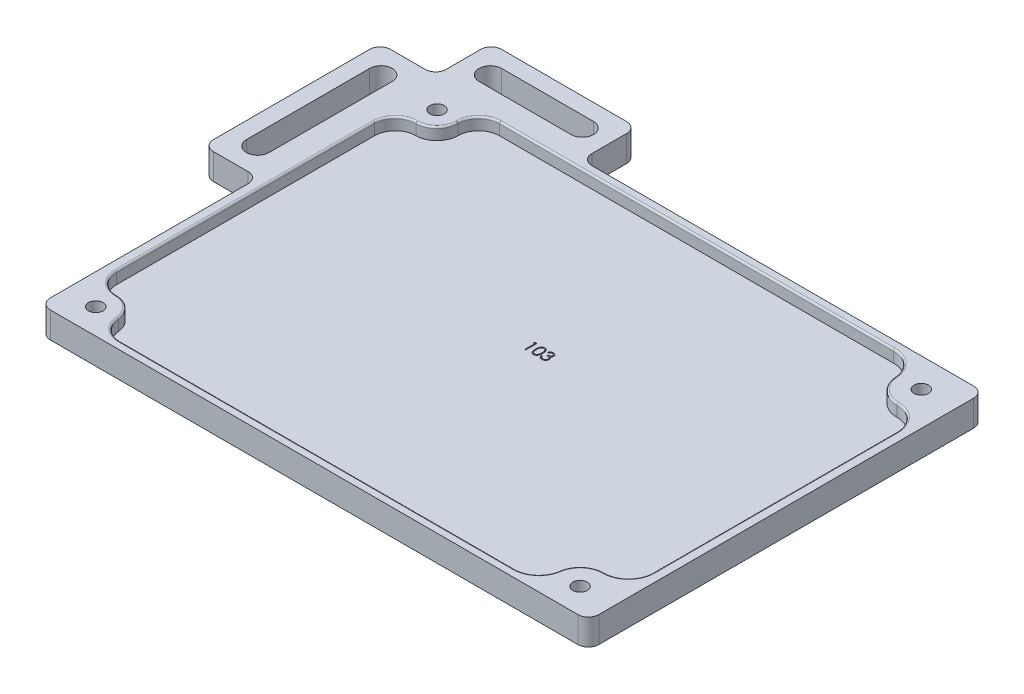
from build123d import *

# Parameters (mm, degrees)
SKETCH1_W           = 158
SKETCH1_H           = 114
SKETCH1_R           = 2.09
BOSS_EXTRUDE1_DEPTH = 7.5
SKETCH1_2_R         = 2.09
BOSS_EXTRUDE2_DEPTH = 2
CUT_EXTRUDE1_DEPTH  = 3.5
SKETCH3_W           = 42
SKETCH3_H           = 16
SKETCH3_W_2         = 16
SKETCH3_H_2         = 51
BOSS_EXTRUDE3_DEPTH = 7.5
FILLET1_R           = 0.5
FILLET2_R           = 3
CUT_EXTRUDE2_DEPTH  = 1


with BuildPart() as part:
    # Sketch1 → Boss-Extrude1 (new body)
    with BuildSketch(Plane(origin=(0, 0, 0), x_dir=(1, 0, 0), z_dir=(0, 1, 0))):
        with Locations((79, 57)):
            Rectangle(SKETCH1_W, SKETCH1_H)
        with Locations((8.75, 105.65)):
            Circle(SKETCH1_R, mode=Mode.SUBTRACT)
        with Locations((8.75, 7.35)):
            Circle(SKETCH1_R, mode=Mode.SUBTRACT)
        with Locations((148.25, 7.35)):
            Circle(SKETCH1_R, mode=Mode.SUBTRACT)
        with Locations((148.25, 105.65)):
            Circle(SKETCH1_R, mode=Mode.SUBTRACT)
    extrude(amount=BOSS_EXTRUDE1_DEPTH)

    # Sketch1_2 → Boss-Extrude2 (add)
    with BuildSketch(Plane(origin=(0, 0, 0), x_dir=(1, 0, 0), z_dir=(0, 1, 0))):
        with Locations((8.75, 105.65)):
            Circle(SKETCH1_2_R)
        with Locations((148.25, 105.65)):
            Circle(SKETCH1_2_R)
        with Locations((8.75, 7.35)):
            Circle(SKETCH1_2_R)
        with Locations((148.25, 7.35)):
            Circle(SKETCH1_2_R)
    extrude(amount=BOSS_EXTRUDE2_DEPTH)

    # Sketch2 → Cut-Extrude1 (cut)
    with BuildSketch(Plane(origin=(0, 7.5, 0), x_dir=(1, 0, 0), z_dir=(0, 1, 0))):
        with BuildLine():
            Line((20.708260743, 2.35), (134.393593539, 2.35))
            ThreePointArc((134.393593539, 2.35), (138.976169234, 4.058497378), (141.32179677, 8.35))
            ThreePointArc((141.32179677, 8.35), (143.667424305, 12.641502622), (148.25, 14.35))
            ThreePointArc((148.25, 14.35), (153.199747468, 16.400252532), (155.25, 21.35))
            Line((155.25, 21.35), (155.25, 91.65))
            ThreePointArc((155.25, 91.65), (153.199747468, 96.599747468), (148.25, 98.65))
            ThreePointArc((148.25, 98.65), (143.480303993, 100.526524617), (141.267879978, 105.15))
            ThreePointArc((141.267879978, 105.15), (139.055455963, 109.773475383), (134.285759956, 111.65))
            Line((134.285759956, 111.65), (20.75, 111.65))
            ThreePointArc((20.75, 111.65), (16.507359313, 109.892640687), (14.75, 105.65))
            ThreePointArc((14.75, 105.65), (12.992640687, 101.407359313), (8.75, 99.65))
            ThreePointArc((8.75, 99.65), (4.507359313, 97.892640687), (2.75, 93.65))
            Line((2.75, 93.65), (2.75, 19.35))
            ThreePointArc((2.75, 19.35), (4.507359313, 15.107359313), (8.75, 13.35))
            ThreePointArc((8.75, 13.35), (12.812019202, 11.765880433), (14.729130372, 7.85))
            ThreePointArc((14.729130372, 7.85), (16.646241541, 3.934119567), (20.708260743, 2.35))
        make_face()
    extrude(amount=-CUT_EXTRUDE1_DEPTH, mode=Mode.SUBTRACT)

    # Sketch3 → Boss-Extrude3 (add)
    with BuildSketch(Plane(origin=(0, 7.5, 0), x_dir=(1, 0, 0), z_dir=(0, 1, 0))):
        with Locations((21, 122)):
            Rectangle(SKETCH3_W, SKETCH3_H)
        with BuildLine():
            ThreePointArc((7.75, 118.75), (4.5, 122), (7.75, 125.25))
            Line((7.75, 125.25), (34.25, 125.25))
            ThreePointArc((34.25, 125.25), (37.5, 122), (34.25, 118.75))
            Line((34.25, 118.75), (7.75, 118.75))
        make_face(mode=Mode.SUBTRACT)
        with Locations((-8, 88.5)):
            Rectangle(SKETCH3_W_2, SKETCH3_H_2)
        with BuildLine():
            ThreePointArc((-4.75, 70.75), (-8, 67.5), (-11.25, 70.75))
            Line((-11.25, 70.75), (-11.25, 106.25))
            ThreePointArc((-11.25, 106.25), (-8, 109.5), (-4.75, 106.25))
            Line((-4.75, 106.25), (-4.75, 70.75))
        make_face(mode=Mode.SUBTRACT)
    extrude(amount=-BOSS_EXTRUDE3_DEPTH)

    # Fillet1
    fillet1_edges = [part.edges().sort_by_distance(p)[0] for p in [
        (139.055455963, 7.5, -109.773475383),
        (77.517879978, 7.5, -111.65),
        (16.507359313, 7.5, -109.892640687),
        (12.992640687, 7.5, -101.407359313),
        (4.507359313, 7.5, -97.892640687),
        (2.75, 7.5, -56.5),
        (4.507359313, 7.5, -15.107359313),
        (12.812019202, 7.5, -11.765880433),
        (16.646241541, 7.5, -3.934119567),
        (77.550927141, 7.5, -2.35),
        (138.976169234, 7.5, -4.058497378),
        (143.667424305, 7.5, -12.641502622),
        (153.199747468, 7.5, -16.400252532),
        (155.25, 7.5, -56.5),
        (153.199747468, 7.5, -96.599747468),
        (143.480303993, 7.5, -100.526524617),
    ]]
    fillet(fillet1_edges, radius=FILLET1_R)

    # Fillet2
    fillet2_edges = [part.edges().sort_by_distance(p)[0] for p in [
        (42, 3.75, -130),
        (0, 3.75, -130),
        (42, 3.75, -114),
        (-16, 3.75, -63),
        (0, 3.75, -63),
        (0, 3.75, -114),
        (-16, 3.75, -114),
        (158, 3.75, -114),
        (158, 3.75, 0),
        (0, 3.75, 0),
    ]]
    fillet(fillet2_edges, radius=FILLET2_R)

    # Sketch4 → Cut-Extrude2 (cut)
    with BuildSketch(Plane(origin=(0, 4, 0), x_dir=(1, 0, 0), z_dir=(0, 1, 0))):
        Polygon((77.37881585, 65.19799426), (77.965860121, 65.19799426), (77.965860121, 62.02299426), (77.680924223, 62.02299426), (77.680924223, 64.872353235), (77.192462685, 64.872353235), align=None)
        with BuildLine():
            add(Edge.make_bspline(
                [(79.146308839, 63.609222225), (79.146606398, 63.66011057), (79.147184411, 63.758961913), (79.153614622, 63.903002266), (79.164296539, 64.038130529), (79.178935442, 64.164353167), (79.196749895, 64.281702768), (79.220531087, 64.389865726), (79.247575558, 64.489342655), (79.278919562, 64.580457942), (79.314287056, 64.664439144), (79.352780993, 64.742839148), (79.395929056, 64.815539329), (79.441265256, 64.883700039), (79.490624778, 64.946205534), (79.542602967, 65.00393852), (79.599228526, 65.055564701), (79.65857654, 65.102596704), (79.721184333, 65.143825868), (79.785267323, 65.180141281), (79.851266598, 65.211165446), (79.919362349, 65.235558913), (79.988942527, 65.255707324), (80.060250366, 65.269485869), (80.133403603, 65.27815535), (80.182780691, 65.278984177), (80.20782226, 65.279404517)],
                knots=[0, 0, 0, 0, 0.000152656, 0.000296537, 0.000432439, 0.000559218, 0.000677689, 0.000788344, 0.000891263, 0.000986803, 0.001077167, 0.001164489, 0.00124859, 0.001330617, 0.001409885, 0.001487322, 0.001563392, 0.001639481, 0.001714274, 0.001788036, 0.00186031, 0.001932743, 0.002004819, 0.002077414, 0.00215039, 0.002225483, 0.002225483, 0.002225483, 0.002225483], degree=3))
            add(Edge.make_bspline(
                [(80.20782226, 65.279404517), (80.233073016, 65.278961999), (80.283288824, 65.27808197), (80.357529735, 65.269623822), (80.430055518, 65.255589303), (80.500556973, 65.235703847), (80.56961321, 65.211033484), (80.636684094, 65.180111599), (80.702186233, 65.144117198), (80.765078708, 65.10182268), (80.826051966, 65.05466733), (80.883608332, 65.001361195), (80.937753046, 64.942442521), (80.989165645, 64.878541687), (81.036387508, 64.808433074), (81.081357693, 64.73333606), (81.121609468, 64.651937347), (81.160375923, 64.565595066), (81.19383769, 64.471920175), (81.224014927, 64.371440714), (81.248397991, 64.262969845), (81.26870826, 64.147076679), (81.284442558, 64.023335605), (81.295902169, 63.892011876), (81.301955611, 63.753019093), (81.303095618, 63.657988758), (81.303680633, 63.609222225)],
                knots=[0, 0, 0, 0, 7.5729e-05, 0.000150601, 0.00022382, 0.00029712, 0.000370151, 0.00044358, 0.000518452, 0.000594128, 0.000670717, 0.000749483, 0.000829148, 0.000910598, 0.000995274, 0.001082536, 0.001172987, 0.001267529, 0.001366317, 0.00147116, 0.001582092, 0.001699622, 0.00182403, 0.001956183, 0.00209498, 0.002241286, 0.002241286, 0.002241286, 0.002241286], degree=3))
            add(Edge.make_bspline(
                [(81.303680633, 63.609222225), (81.303089553, 63.560668394), (81.301937857, 63.466063235), (81.295970031, 63.32769585), (81.284214701, 63.197069054), (81.269509926, 63.073869563), (81.249143695, 62.958610152), (81.224101866, 62.850891973), (81.196297644, 62.750249851), (81.161976081, 62.657508272), (81.124410651, 62.571373495), (81.083539152, 62.490939725), (81.039751524, 62.415496016), (80.992046019, 62.345646246), (80.941197566, 62.280895607), (80.886117857, 62.222387049), (80.828359541, 62.168710797), (80.767206849, 62.120948249), (80.703333514, 62.079142748), (80.638056351, 62.041755898), (80.570217139, 62.011609096), (80.501353246, 61.985723737), (80.430479657, 61.965947613), (80.357684717, 61.952273473), (80.283338703, 61.942683296), (80.233081569, 61.941951703), (80.20782226, 61.941584004)],
                knots=[0, 0, 0, 0, 0.00014567, 0.000283833, 0.000415351, 0.000539048, 0.000655953, 0.000766265, 0.000870752, 0.000968942, 0.001062646, 0.001152529, 0.001239469, 0.001324145, 0.001406093, 0.001486191, 0.001564957, 0.001642439, 0.001718644, 0.001793826, 0.001867834, 0.001941084, 0.002014383, 0.002088227, 0.002163172, 0.002238901, 0.002238901, 0.002238901, 0.002238901], degree=3))
            add(Edge.make_bspline(
                [(80.20782226, 61.941584004), (80.182781385, 61.942007055), (80.133405668, 61.942841229), (80.060242396, 61.951471543), (79.989229037, 61.965346749), (79.920015167, 61.984774669), (79.852245685, 62.00855527), (79.786844054, 62.03953754), (79.723083084, 62.07521916), (79.661132887, 62.115855006), (79.602157569, 62.162411105), (79.545825263, 62.213904424), (79.493551138, 62.271619947), (79.444897352, 62.334646349), (79.398656572, 62.40240379), (79.356121211, 62.475817385), (79.316777651, 62.554596039), (79.280815342, 62.639248715), (79.248930483, 62.731010686), (79.220765776, 62.830931726), (79.198527933, 62.939893767), (79.179493395, 63.057021665), (79.164140562, 63.18281873), (79.153659138, 63.317353257), (79.147180945, 63.460541411), (79.146604846, 63.558757564), (79.146308839, 63.609222225)],
                knots=[0, 0, 0, 0, 7.5093e-05, 0.000148069, 0.000220664, 0.000291955, 0.000363574, 0.000435848, 0.000508744, 0.000582656, 0.000657851, 0.000733921, 0.000811359, 0.000891128, 0.000972628, 0.001057278, 0.001145453, 0.00123665, 0.001333, 0.001436702, 0.001547845, 0.001666417, 0.001792639, 0.001927908, 0.002071153, 0.002222537, 0.002222537, 0.002222537, 0.002222537], degree=3))
        make_face()
        with BuildLine():
            add(Edge.make_bspline(
                [(79.431244736, 63.61049426), (79.431353092, 63.568086512), (79.431563388, 63.4857814), (79.437057228, 63.366180728), (79.444541367, 63.254629072), (79.454194543, 63.150984793), (79.468530075, 63.05559871), (79.484592661, 62.967814783), (79.504139857, 62.888097575), (79.52726748, 62.815900061), (79.55361009, 62.749996978), (79.582371837, 62.688673018), (79.613269779, 62.631203762), (79.647849294, 62.578105417), (79.685509387, 62.529204825), (79.725399415, 62.48363647), (79.769008116, 62.442999209), (79.829336511, 62.394261276), (79.908980456, 62.34389749), (80.009329012, 62.30004068), (80.112442535, 62.272479452), (80.182429741, 62.268974473), (80.217362525, 62.26722503)],
                knots=[0, 0, 0, 0, 0.00012721, 0.000246889, 0.000359088, 0.000462625, 0.000559048, 0.000648362, 0.000730273, 0.000805096, 0.000875606, 0.000943038, 0.001008214, 0.001071192, 0.001132889, 0.001193261, 0.001252653, 0.001311456, 0.001425798, 0.001534033, 0.001639084, 0.00174377, 0.00174377, 0.00174377, 0.00174377], degree=3))
            add(Edge.make_bspline(
                [(80.217362525, 62.26722503), (80.25252127, 62.268674445), (80.32276617, 62.271570284), (80.425394684, 62.299509138), (80.525026429, 62.341663649), (80.603105975, 62.391508886), (80.662507996, 62.438978156), (80.705068409, 62.479450016), (80.744131839, 62.524767124), (80.781181435, 62.573661485), (80.815162168, 62.627067239), (80.8460623, 62.684727575), (80.874259337, 62.746802615), (80.890323971, 62.790136593), (80.898537404, 62.812292137)],
                knots=[0, 0, 0, 0, 0.000105268, 0.000210319, 0.000316882, 0.000428931, 0.00048684, 0.000544871, 0.000604822, 0.000666135, 0.000728769, 0.000794503, 0.000862248, 0.000933117, 0.000933117, 0.000933117, 0.000933117], degree=3))
            add(Edge.make_bspline(
                [(80.898537404, 62.812292137), (80.908109365, 62.840621972), (80.927544551, 62.898143687), (80.952592374, 62.987373571), (80.972318558, 63.080993221), (80.990065325, 63.178443149), (81.002178455, 63.28044202), (81.011928257, 63.38667424), (81.017671094, 63.497219904), (81.018382975, 63.572326789), (81.018744736, 63.61049426)],
                knots=[0, 0, 0, 0, 8.9703e-05, 0.000182136, 0.00027782, 0.000376635, 0.000479189, 0.000585832, 0.000696647, 0.000811146, 0.000811146, 0.000811146, 0.000811146], degree=3))
            add(Edge.make_bspline(
                [(81.018744736, 63.61049426), (81.018245636, 63.648655558), (81.017269289, 63.723307215), (81.013537315, 63.832634422), (81.003900215, 63.936473033), (80.993196728, 64.035270391), (80.977414964, 64.128479594), (80.960398953, 64.216880942), (80.937537853, 64.299379258), (80.913117772, 64.377266164), (80.885168341, 64.449656758), (80.854401925, 64.51688855), (80.821543616, 64.579286121), (80.785854583, 64.636678275), (80.747758499, 64.689322082), (80.706249865, 64.736162036), (80.662975184, 64.778649857), (80.602362452, 64.827148045), (80.523010774, 64.87659794), (80.424272223, 64.922105451), (80.321519567, 64.948238687), (80.252056505, 64.951923218), (80.217362525, 64.953763491)],
                knots=[0, 0, 0, 0, 0.000114499, 0.000223985, 0.000328037, 0.000427282, 0.000522015, 0.000611574, 0.0006972, 0.000778663, 0.000856382, 0.000929811, 0.001000372, 0.00106779, 0.001132413, 0.001195057, 0.001255328, 0.001314131, 0.001427596, 0.001534925, 0.001639202, 0.001743255, 0.001743255, 0.001743255, 0.001743255], degree=3))
            add(Edge.make_bspline(
                [(80.217362525, 64.953763491), (80.182246487, 64.951920679), (80.11195044, 64.948231697), (80.008129796, 64.922202817), (79.908612277, 64.876833912), (79.829470435, 64.82698426), (79.768815429, 64.779505935), (79.7261047, 64.738333937), (79.686057815, 64.693297692), (79.649166401, 64.643947384), (79.61461398, 64.590910943), (79.582881205, 64.533771135), (79.554290484, 64.472238398), (79.527906655, 64.406364917), (79.504708483, 64.334173632), (79.485573245, 64.254554616), (79.467895704, 64.1670499), (79.455381424, 64.071147203), (79.444256446, 63.967476964), (79.437106937, 63.855646826), (79.431545011, 63.735845566), (79.431346832, 63.653114901), (79.431244736, 63.61049426)],
                knots=[0, 0, 0, 0, 0.00010532, 0.000210832, 0.000318741, 0.000432206, 0.000490612, 0.000549543, 0.000609914, 0.000671226, 0.000734205, 0.000799687, 0.00086712, 0.000937629, 0.001012452, 0.001094363, 0.001183173, 0.001280136, 0.001384369, 0.001495934, 0.001616249, 0.001744095, 0.001744095, 0.001744095, 0.001744095], degree=3))
        make_face(mode=Mode.SUBTRACT)
        with BuildLine():
            Line((81.995667813, 64.465301953), (81.710731916, 64.465301953))
            add(Edge.make_bspline(
                [(81.710731916, 64.465301953), (81.718451294, 64.497262849), (81.733542046, 64.559743787), (81.765017702, 64.649013231), (81.799307027, 64.733489568), (81.840481429, 64.811591006), (81.885392942, 64.884887154), (81.936848553, 64.951715574), (81.992474302, 65.013775907), (82.05400122, 65.068851486), (82.118525077, 65.118724141), (82.186955054, 65.161246514), (82.257914393, 65.197826281), (82.331894735, 65.227961777), (82.409116334, 65.250663502), (82.488881063, 65.267134319), (82.571397953, 65.277830544), (82.627411838, 65.278874451), (82.655854111, 65.279404517)],
                knots=[0, 0, 0, 0, 9.8575e-05, 0.000192705, 0.000283656, 0.000371842, 0.000457261, 0.000541217, 0.000624516, 0.000706917, 0.000788585, 0.000868879, 0.000948242, 0.001027846, 0.001108138, 0.001189341, 0.001272016, 0.001357302, 0.001357302, 0.001357302, 0.001357302], degree=3))
            add(Edge.make_bspline(
                [(82.655854111, 65.279404517), (82.697294884, 65.278153358), (82.779272487, 65.275678332), (82.899707537, 65.253077379), (83.015846151, 65.217313151), (83.126417112, 65.167897699), (83.229122404, 65.106949208), (83.320504516, 65.034409768), (83.399324808, 64.951678973), (83.465450422, 64.860300147), (83.5172256, 64.76264122), (83.555403953, 64.662129649), (83.578646478, 64.559003861), (83.581658697, 64.489374043), (83.583167813, 64.454489653)],
                knots=[0, 0, 0, 0, 0.000124221, 0.000245732, 0.000366235, 0.000488093, 0.000608186, 0.000723607, 0.000836972, 0.000949947, 0.001060913, 0.001167586, 0.001271755, 0.001376341, 0.001376341, 0.001376341, 0.001376341], degree=3))
            add(Edge.make_bspline(
                [(83.583167813, 64.454489653), (83.58211227, 64.420919204), (83.580046735, 64.355227043), (83.562508302, 64.259322542), (83.532993264, 64.168933377), (83.492108551, 64.083679037), (83.43918443, 64.004100075), (83.375074198, 63.930017445), (83.299325355, 63.861102566), (83.241922318, 63.821624187), (83.212369536, 63.801299549)],
                knots=[0, 0, 0, 0, 0.000100654, 0.000196964, 0.000291294, 0.000385168, 0.000479719, 0.000577128, 0.000678438, 0.000785942, 0.000785942, 0.000785942, 0.000785942], degree=3))
            add(Edge.make_bspline(
                [(83.212369536, 63.801299549), (83.246144056, 63.784990779), (83.313061149, 63.752678389), (83.404274844, 63.689309237), (83.487076916, 63.616142408), (83.533253861, 63.55904443), (83.556455073, 63.530356039)],
                knots=[0, 0, 0, 0, 0.000112361, 0.00022262, 0.000332061, 0.000442576, 0.000442576, 0.000442576, 0.000442576], degree=3))
            add(Edge.make_bspline(
                [(83.556455073, 63.530356039), (83.571732576, 63.509439365), (83.602037403, 63.46794854), (83.639443923, 63.401240497), (83.673379334, 63.333793074), (83.699822747, 63.26379847), (83.720300469, 63.192067951), (83.734938156, 63.118478349), (83.744031483, 63.042969571), (83.745333734, 62.991886107), (83.745988326, 62.966208403)],
                knots=[0, 0, 0, 0, 7.7636e-05, 0.000154, 0.000229094, 0.000303982, 0.000378066, 0.000452657, 0.000528865, 0.000605889, 0.000605889, 0.000605889, 0.000605889], degree=3))
            add(Edge.make_bspline(
                [(83.745988326, 62.966208403), (83.744360446, 62.921749585), (83.741112346, 62.833041171), (83.712080079, 62.70198196), (83.667073782, 62.573870254), (83.603159276, 62.451338078), (83.525265178, 62.336693019), (83.432593892, 62.234116652), (83.326198364, 62.145943633), (83.207538954, 62.072274355), (83.078981273, 62.013384525), (82.941480557, 61.972510988), (82.797018008, 61.945889974), (82.697951389, 61.943035314), (82.647585882, 61.941584004)],
                knots=[0, 0, 0, 0, 0.000133226, 0.000265824, 0.000400805, 0.00053962, 0.000679164, 0.000815599, 0.000952897, 0.001092317, 0.00123349, 0.001375737, 0.001521711, 0.001672674, 0.001672674, 0.001672674, 0.001672674], degree=3))
            add(Edge.make_bspline(
                [(82.647585882, 61.941584004), (82.613641231, 61.942371597), (82.546849477, 61.943921319), (82.448657161, 61.954515478), (82.354929619, 61.97386484), (82.265540127, 61.999902839), (82.180409272, 62.032915348), (82.099796834, 62.074025881), (82.023206859, 62.122387029), (81.951362096, 62.178569641), (81.88427111, 62.241417713), (81.823716853, 62.312046958), (81.768689755, 62.389151746), (81.720663219, 62.473627661), (81.677449697, 62.564383002), (81.641906972, 62.662579854), (81.610623635, 62.76734036), (81.596078992, 62.840345167), (81.588616531, 62.877801953)],
                knots=[0, 0, 0, 0, 0.000101834, 0.000200376, 0.000295798, 0.00038858, 0.000479406, 0.000569289, 0.000659631, 0.000750724, 0.000842509, 0.00093495, 0.001029366, 0.001126242, 0.001226104, 0.001330545, 0.001439228, 0.001553746, 0.001553746, 0.001553746, 0.001553746], degree=3))
            Line((81.588616531, 62.877801953), (81.873552428, 62.877801953))
            add(Edge.make_bspline(
                [(81.873552428, 62.877801953), (81.880975843, 62.853355348), (81.895415029, 62.805804578), (81.919993427, 62.737369443), (81.94799536, 62.674633209), (81.978034995, 62.617135663), (82.009584014, 62.564310555), (82.044885411, 62.517554717), (82.081324564, 62.474814498), (82.108792263, 62.450734743), (82.122235321, 62.438949789)],
                knots=[0, 0, 0, 0, 7.6642e-05, 0.000149076, 0.00021798, 0.000282557, 0.000343641, 0.000402283, 0.000458165, 0.000511731, 0.000511731, 0.000511731, 0.000511731], degree=3))
            add(Edge.make_bspline(
                [(82.122235321, 62.438949789), (82.140012215, 62.425244372), (82.175511131, 62.397875843), (82.233358026, 62.362949366), (82.294195459, 62.33268615), (82.359341628, 62.309568798), (82.427390741, 62.289994777), (82.499442708, 62.277185449), (82.574861855, 62.268396893), (82.626358326, 62.267621348), (82.652674023, 62.26722503)],
                knots=[0, 0, 0, 0, 6.7292e-05, 0.000134376, 0.000202358, 0.000270771, 0.000341449, 0.00041455, 0.000490054, 0.000568961, 0.000568961, 0.000568961, 0.000568961], degree=3))
            add(Edge.make_bspline(
                [(82.652674023, 62.26722503), (82.682386129, 62.267783744), (82.740485587, 62.268876261), (82.825262495, 62.278923509), (82.905914251, 62.293556098), (82.981545405, 62.316155733), (83.053146651, 62.344078362), (83.119714291, 62.379137987), (83.182122187, 62.420272128), (83.239571005, 62.467025507), (83.291228715, 62.518207864), (83.336712416, 62.57174115), (83.375379074, 62.627399652), (83.406569891, 62.685491376), (83.431199319, 62.745775762), (83.447966222, 62.808421986), (83.459624382, 62.872917363), (83.460573809, 62.916758642), (83.461052428, 62.938859645)],
                knots=[0, 0, 0, 0, 8.9099e-05, 0.000174226, 0.000255805, 0.000334697, 0.000410639, 0.000486028, 0.00055994, 0.000634539, 0.000707846, 0.0007778, 0.000845016, 0.000910751, 0.000975237, 0.001039889, 0.001105031, 0.001171253, 0.001171253, 0.001171253, 0.001171253], degree=3))
            add(Edge.make_bspline(
                [(83.461052428, 62.938859645), (83.459664226, 62.968442788), (83.45689473, 63.027461873), (83.435750518, 63.114291387), (83.400971691, 63.197951196), (83.352283056, 63.277013949), (83.293014217, 63.350289231), (83.223740337, 63.415668362), (83.143886158, 63.46961623), (83.070389563, 63.506889511), (83.005288314, 63.532323143), (82.949575786, 63.549264004), (82.887203725, 63.563609249), (82.818926394, 63.576955381), (82.744229333, 63.588314032), (82.663193865, 63.597786251), (82.575803566, 63.605365467), (82.515305152, 63.608750103), (82.484129351, 63.61049426)],
                knots=[0, 0, 0, 0, 8.8683e-05, 0.000176924, 0.000266456, 0.0003595, 0.00045446, 0.000548507, 0.000644124, 0.00074254, 0.000795099, 0.000853644, 0.000917048, 0.000987025, 0.001062314, 0.00114365, 0.001231751, 0.001325421, 0.001325421, 0.001325421, 0.001325421], degree=3))
            Line((82.484129351, 63.61049426), (82.484129351, 63.936135286))
            add(Edge.make_bspline(
                [(82.484129351, 63.936135286), (82.523409695, 63.936801858), (82.600350238, 63.938107509), (82.712740071, 63.953899061), (82.82021229, 63.975743631), (82.92038512, 64.009203769), (83.011687882, 64.048066039), (83.090899235, 64.093289115), (83.156909433, 64.143558208), (83.209397691, 64.199649218), (83.248884919, 64.25980644), (83.277756371, 64.322505122), (83.294810953, 64.388294806), (83.297087579, 64.433193541), (83.298231916, 64.455761688)],
                knots=[0, 0, 0, 0, 0.000117747, 0.000230638, 0.000339915, 0.000446313, 0.000546864, 0.000637192, 0.000719248, 0.000794851, 0.00086647, 0.000934214, 0.001001162, 0.001068823, 0.001068823, 0.001068823, 0.001068823], degree=3))
            add(Edge.make_bspline(
                [(83.298231916, 64.455761688), (83.297855986, 64.472342214), (83.297108091, 64.505328384), (83.287676275, 64.553520411), (83.273503037, 64.600239126), (83.254017854, 64.645285854), (83.227937317, 64.688348174), (83.196726172, 64.729793217), (83.159562252, 64.769384359), (83.116976026, 64.806287221), (83.071245317, 64.841456457), (83.021125878, 64.871313828), (82.968128892, 64.89684542), (82.912195683, 64.917899754), (82.853144738, 64.933737822), (82.791253503, 64.945109621), (82.726403962, 64.952219494), (82.682161034, 64.953243128), (82.659670217, 64.953763491)],
                knots=[0, 0, 0, 0, 4.9675e-05, 9.8825e-05, 0.000146708, 0.000195982, 0.000245612, 0.000297384, 0.000351382, 0.000408162, 0.000466295, 0.000524214, 0.000582814, 0.00064259, 0.000703225, 0.000765972, 0.000831222, 0.000898688, 0.000898688, 0.000898688, 0.000898688], degree=3))
            add(Edge.make_bspline(
                [(82.659670217, 64.953763491), (82.623519061, 64.952501327), (82.552907445, 64.950036027), (82.451112485, 64.928443293), (82.356479946, 64.893991746), (82.284145584, 64.852868221), (82.230730678, 64.812273185), (82.192560884, 64.776819877), (82.155077278, 64.737420102), (82.120745842, 64.691647147), (82.086025878, 64.642600844), (82.054416883, 64.587787933), (82.023701305, 64.528638233), (82.005193278, 64.486822907), (81.995667813, 64.465301953)],
                knots=[0, 0, 0, 0, 0.000108349, 0.000211631, 0.000310638, 0.000409485, 0.000459859, 0.000511627, 0.000565625, 0.000622746, 0.000683084, 0.000745805, 0.000812368, 0.000882955, 0.000882955, 0.000882955, 0.000882955], degree=3))
        make_face()
    extrude(amount=-CUT_EXTRUDE2_DEPTH, mode=Mode.SUBTRACT)


solid = part.part
